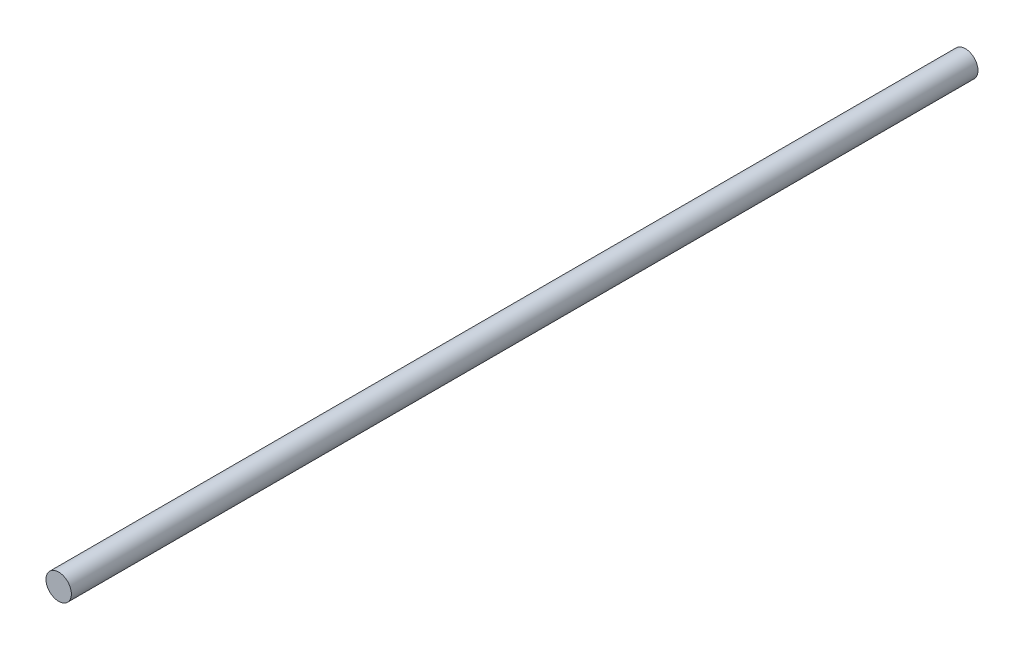
from build123d import *

# Parameters (mm, degrees)
SKETCH1_R           = 3.5
BOSS_EXTRUDE1_DEPTH = 250


with BuildPart() as part:
    # Sketch1 → Boss-Extrude1 (new body)
    with BuildSketch(Plane.XY):
        Circle(SKETCH1_R)
    extrude(amount=BOSS_EXTRUDE1_DEPTH)


solid = part.part
